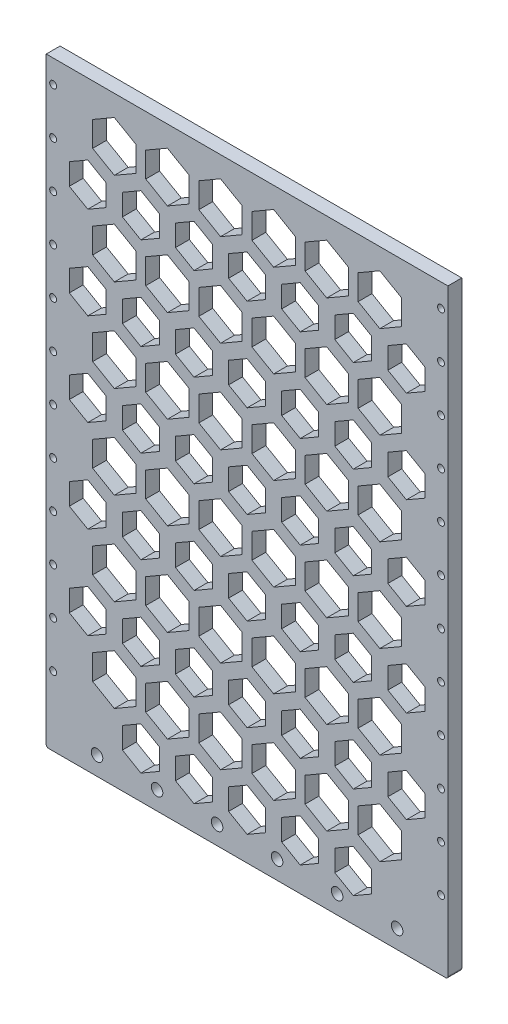
from build123d import *

# Parameters (mm, degrees)
SKETCH1_W           = 174
SKETCH1_H           = 240
BOSS_EXTRUDE1_DEPTH = 6
SKETCH3_R           = 2.5
CUT_EXTRUDE1_DEPTH  = 6
SKETCH4_W           = 174
SKETCH4_H           = 6
BOSS_EXTRUDE2_DEPTH = 20
SKETCH6_R           = 1.5
CUT_EXTRUDE2_DEPTH  = 10
CUT_EXTRUDE3_DEPTH  = 10
FILLET2_R           = 1


with BuildPart() as part:
    # Sketch1 → Boss-Extrude1 (new body)
    with BuildSketch(Plane.XY):
        with Locations((0, -30)):
            Rectangle(SKETCH1_W, SKETCH1_H)
    extrude(amount=BOSS_EXTRUDE1_DEPTH)

    # Sketch3 → Cut-Extrude1 (cut)
    with BuildSketch(Plane.XY.offset(6)):
        with Locations((-65, -142)):
            Circle(SKETCH3_R)
        with Locations((-39, -142)):
            Circle(SKETCH3_R)
        with Locations((-13, -142)):
            Circle(SKETCH3_R)
        with Locations((13, -142)):
            Circle(SKETCH3_R)
        with Locations((39, -142)):
            Circle(SKETCH3_R)
        with Locations((65, -142)):
            Circle(SKETCH3_R)
    extrude(amount=-CUT_EXTRUDE1_DEPTH, mode=Mode.SUBTRACT)

    # Sketch4 → Boss-Extrude2 (add)
    with BuildSketch(Plane(origin=(0, 90, 0), x_dir=(1, 0, 0), z_dir=(0, 1, 0))):
        with Locations((0, -3)):
            Rectangle(SKETCH4_W, SKETCH4_H)
    extrude(amount=BOSS_EXTRUDE2_DEPTH)

    # Sketch6 → Cut-Extrude2 (cut)
    with BuildSketch(Plane.XY.offset(6)):
        with Locations((-84, 100)):
            Circle(SKETCH6_R)
        with Locations((-84, 80)):
            Circle(SKETCH6_R)
        with Locations((-84, 60)):
            Circle(SKETCH6_R)
        with Locations((-84, 40)):
            Circle(SKETCH6_R)
        with Locations((-84, 20)):
            Circle(SKETCH6_R)
        with Locations((-84, 0)):
            Circle(SKETCH6_R)
        with Locations((-84, -20)):
            Circle(SKETCH6_R)
        with Locations((-84, -40)):
            Circle(SKETCH6_R)
        with Locations((-84, -60)):
            Circle(SKETCH6_R)
        with Locations((-84, -80)):
            Circle(SKETCH6_R)
        with Locations((-84, -100)):
            Circle(SKETCH6_R)
        with Locations((-84, -120)):
            Circle(SKETCH6_R)
        with Locations((84, 100)):
            Circle(SKETCH6_R)
        with Locations((84, 80)):
            Circle(SKETCH6_R)
        with Locations((84, 60)):
            Circle(SKETCH6_R)
        with Locations((84, 40)):
            Circle(SKETCH6_R)
        with Locations((84, 20)):
            Circle(SKETCH6_R)
        with Locations((84, 0)):
            Circle(SKETCH6_R)
        with Locations((84, -20)):
            Circle(SKETCH6_R)
        with Locations((84, -40)):
            Circle(SKETCH6_R)
        with Locations((84, -60)):
            Circle(SKETCH6_R)
        with Locations((84, -80)):
            Circle(SKETCH6_R)
        with Locations((84, -100)):
            Circle(SKETCH6_R)
        with Locations((84, -120)):
            Circle(SKETCH6_R)
    extrude(amount=-CUT_EXTRUDE2_DEPTH, mode=Mode.SUBTRACT)

    # Sketch7 → Cut-Extrude3 (cut)
    with BuildSketch(Plane.XY.offset(6)):
        Polygon((-46, 60.762395693), (-38, 65.381197846), (-38, 74.618802154), (-46, 79.237604307), (-54, 74.618802154), (-54, 65.381197846), align=None)
        Polygon((-23, 60.762395693), (-15, 65.381197846), (-15, 74.618802154), (-23, 79.237604307), (-31, 74.618802154), (-31, 65.381197846), align=None)
        Polygon((0, 60.762395693), (8, 65.381197846), (8, 74.618802154), (0, 79.237604307), (-8, 74.618802154), (-8, 65.381197846), align=None)
        Polygon((23, 60.762395693), (31, 65.381197846), (31, 74.618802154), (23, 79.237604307), (15, 74.618802154), (15, 65.381197846), align=None)
        Polygon((46, 60.762395693), (54, 65.381197846), (54, 74.618802154), (46, 79.237604307), (38, 74.618802154), (38, 65.381197846), align=None)
        Polygon((69, 60.762395693), (77, 65.381197846), (77, 74.618802154), (69, 79.237604307), (61, 74.618802154), (61, 65.381197846), align=None)
        Polygon((-46, 20.762395693), (-38, 25.381197846), (-38, 34.618802154), (-46, 39.237604307), (-54, 34.618802154), (-54, 25.381197846), align=None)
        Polygon((-23, 20.762395693), (-15, 25.381197846), (-15, 34.618802154), (-23, 39.237604307), (-31, 34.618802154), (-31, 25.381197846), align=None)
        Polygon((0, 20.762395693), (8, 25.381197846), (8, 34.618802154), (0, 39.237604307), (-8, 34.618802154), (-8, 25.381197846), align=None)
        Polygon((23, 20.762395693), (31, 25.381197846), (31, 34.618802154), (23, 39.237604307), (15, 34.618802154), (15, 25.381197846), align=None)
        Polygon((46, 20.762395693), (54, 25.381197846), (54, 34.618802154), (46, 39.237604307), (38, 34.618802154), (38, 25.381197846), align=None)
        Polygon((69, 20.762395693), (77, 25.381197846), (77, 34.618802154), (69, 39.237604307), (61, 34.618802154), (61, 25.381197846), align=None)
        Polygon((-46, -19.237604307), (-38, -14.618802154), (-38, -5.381197846), (-46, -0.762395693), (-54, -5.381197846), (-54, -14.618802154), align=None)
        Polygon((-23, -19.237604307), (-15, -14.618802154), (-15, -5.381197846), (-23, -0.762395693), (-31, -5.381197846), (-31, -14.618802154), align=None)
        Polygon((0, -19.237604307), (8, -14.618802154), (8, -5.381197846), (0, -0.762395693), (-8, -5.381197846), (-8, -14.618802154), align=None)
        Polygon((23, -19.237604307), (31, -14.618802154), (31, -5.381197846), (23, -0.762395693), (15, -5.381197846), (15, -14.618802154), align=None)
        Polygon((46, -19.237604307), (54, -14.618802154), (54, -5.381197846), (46, -0.762395693), (38, -5.381197846), (38, -14.618802154), align=None)
        Polygon((69, -19.237604307), (77, -14.618802154), (77, -5.381197846), (69, -0.762395693), (61, -5.381197846), (61, -14.618802154), align=None)
        Polygon((-46, -59.237604307), (-38, -54.618802154), (-38, -45.381197846), (-46, -40.762395693), (-54, -45.381197846), (-54, -54.618802154), align=None)
        Polygon((-23, -59.237604307), (-15, -54.618802154), (-15, -45.381197846), (-23, -40.762395693), (-31, -45.381197846), (-31, -54.618802154), align=None)
        Polygon((0, -59.237604307), (8, -54.618802154), (8, -45.381197846), (0, -40.762395693), (-8, -45.381197846), (-8, -54.618802154), align=None)
        Polygon((23, -59.237604307), (31, -54.618802154), (31, -45.381197846), (23, -40.762395693), (15, -45.381197846), (15, -54.618802154), align=None)
        Polygon((46, -59.237604307), (54, -54.618802154), (54, -45.381197846), (46, -40.762395693), (38, -45.381197846), (38, -54.618802154), align=None)
        Polygon((69, -59.237604307), (77, -54.618802154), (77, -45.381197846), (69, -40.762395693), (61, -45.381197846), (61, -54.618802154), align=None)
        Polygon((-46, -99.237604307), (-38, -94.618802154), (-38, -85.381197846), (-46, -80.762395693), (-54, -85.381197846), (-54, -94.618802154), align=None)
        Polygon((-23, -99.237604307), (-15, -94.618802154), (-15, -85.381197846), (-23, -80.762395693), (-31, -85.381197846), (-31, -94.618802154), align=None)
        Polygon((0, -99.237604307), (8, -94.618802154), (8, -85.381197846), (0, -80.762395693), (-8, -85.381197846), (-8, -94.618802154), align=None)
        Polygon((23, -99.237604307), (31, -94.618802154), (31, -85.381197846), (23, -80.762395693), (15, -85.381197846), (15, -94.618802154), align=None)
        Polygon((46, -99.237604307), (54, -94.618802154), (54, -85.381197846), (46, -80.762395693), (38, -85.381197846), (38, -94.618802154), align=None)
        Polygon((69, -99.237604307), (77, -94.618802154), (77, -85.381197846), (69, -80.762395693), (61, -85.381197846), (61, -94.618802154), align=None)
        Polygon((-46, -139.237604307), (-38, -134.618802154), (-38, -125.381197846), (-46, -120.762395693), (-54, -125.381197846), (-54, -134.618802154), align=None)
        Polygon((-23, -139.237604307), (-15, -134.618802154), (-15, -125.381197846), (-23, -120.762395693), (-31, -125.381197846), (-31, -134.618802154), align=None)
        Polygon((0, -139.237604307), (8, -134.618802154), (8, -125.381197846), (0, -120.762395693), (-8, -125.381197846), (-8, -134.618802154), align=None)
        Polygon((23, -139.237604307), (31, -134.618802154), (31, -125.381197846), (23, -120.762395693), (15, -125.381197846), (15, -134.618802154), align=None)
        Polygon((46, -139.237604307), (54, -134.618802154), (54, -125.381197846), (46, -120.762395693), (38, -125.381197846), (38, -134.618802154), align=None)
        Polygon((-69, 60.762395693), (-61, 65.381197846), (-61, 74.618802154), (-69, 79.237604307), (-77, 74.618802154), (-77, 65.381197846), align=None)
        Polygon((-69, 20.762395693), (-61, 25.381197846), (-61, 34.618802154), (-69, 39.237604307), (-77, 34.618802154), (-77, 25.381197846), align=None)
        Polygon((-69, -19.237604307), (-61, -14.618802154), (-61, -5.381197846), (-69, -0.762395693), (-77, -5.381197846), (-77, -14.618802154), align=None)
        Polygon((-69, -59.237604307), (-61, -54.618802154), (-61, -45.381197846), (-69, -40.762395693), (-77, -45.381197846), (-77, -54.618802154), align=None)
        Polygon((-69, -99.237604307), (-61, -94.618802154), (-61, -85.381197846), (-69, -80.762395693), (-77, -85.381197846), (-77, -94.618802154), align=None)
        Polygon((-34.5, 79.237604307), (-25.108983849, 84.65951001), (-25.108983849, 95.503321416), (-34.5, 100.925227119), (-43.891016151, 95.503321416), (-43.891016151, 84.65951001), align=None)
        Polygon((-11.5, 79.237604307), (-2.108983849, 84.65951001), (-2.108983849, 95.503321416), (-11.5, 100.925227119), (-20.891016151, 95.503321416), (-20.891016151, 84.65951001), align=None)
        Polygon((11.5, 79.237604307), (20.891016151, 84.65951001), (20.891016151, 95.503321416), (11.5, 100.925227119), (2.108983849, 95.503321416), (2.108983849, 84.65951001), align=None)
        Polygon((34.5, 79.237604307), (43.891016151, 84.65951001), (43.891016151, 95.503321416), (34.5, 100.925227119), (25.108983849, 95.503321416), (25.108983849, 84.65951001), align=None)
        Polygon((57.5, 79.237604307), (66.891016151, 84.65951001), (66.891016151, 95.503321416), (57.5, 100.925227119), (48.108983849, 95.503321416), (48.108983849, 84.65951001), align=None)
        Polygon((-34.5, 39.237604307), (-25.108983849, 44.65951001), (-25.108983849, 55.503321416), (-34.5, 60.925227119), (-43.891016151, 55.503321416), (-43.891016151, 44.65951001), align=None)
        Polygon((-11.5, 39.237604307), (-2.108983849, 44.65951001), (-2.108983849, 55.503321416), (-11.5, 60.925227119), (-20.891016151, 55.503321416), (-20.891016151, 44.65951001), align=None)
        Polygon((11.5, 39.237604307), (20.891016151, 44.65951001), (20.891016151, 55.503321416), (11.5, 60.925227119), (2.108983849, 55.503321416), (2.108983849, 44.65951001), align=None)
        Polygon((34.5, 39.237604307), (43.891016151, 44.65951001), (43.891016151, 55.503321416), (34.5, 60.925227119), (25.108983849, 55.503321416), (25.108983849, 44.65951001), align=None)
        Polygon((57.5, 39.237604307), (66.891016151, 44.65951001), (66.891016151, 55.503321416), (57.5, 60.925227119), (48.108983849, 55.503321416), (48.108983849, 44.65951001), align=None)
        Polygon((-34.5, -0.762395693), (-25.108983849, 4.65951001), (-25.108983849, 15.503321416), (-34.5, 20.925227119), (-43.891016151, 15.503321416), (-43.891016151, 4.65951001), align=None)
        Polygon((-11.5, -0.762395693), (-2.108983849, 4.65951001), (-2.108983849, 15.503321416), (-11.5, 20.925227119), (-20.891016151, 15.503321416), (-20.891016151, 4.65951001), align=None)
        Polygon((11.5, -0.762395693), (20.891016151, 4.65951001), (20.891016151, 15.503321416), (11.5, 20.925227119), (2.108983849, 15.503321416), (2.108983849, 4.65951001), align=None)
        Polygon((34.5, -0.762395693), (43.891016151, 4.65951001), (43.891016151, 15.503321416), (34.5, 20.925227119), (25.108983849, 15.503321416), (25.108983849, 4.65951001), align=None)
        Polygon((57.5, -0.762395693), (66.891016151, 4.65951001), (66.891016151, 15.503321416), (57.5, 20.925227119), (48.108983849, 15.503321416), (48.108983849, 4.65951001), align=None)
        Polygon((-34.5, -40.762395693), (-25.108983849, -35.34048999), (-25.108983849, -24.496678584), (-34.5, -19.074772881), (-43.891016151, -24.496678584), (-43.891016151, -35.34048999), align=None)
        Polygon((-11.5, -40.762395693), (-2.108983849, -35.34048999), (-2.108983849, -24.496678584), (-11.5, -19.074772881), (-20.891016151, -24.496678584), (-20.891016151, -35.34048999), align=None)
        Polygon((11.5, -40.762395693), (20.891016151, -35.34048999), (20.891016151, -24.496678584), (11.5, -19.074772881), (2.108983849, -24.496678584), (2.108983849, -35.34048999), align=None)
        Polygon((34.5, -40.762395693), (43.891016151, -35.34048999), (43.891016151, -24.496678584), (34.5, -19.074772881), (25.108983849, -24.496678584), (25.108983849, -35.34048999), align=None)
        Polygon((57.5, -40.762395693), (66.891016151, -35.34048999), (66.891016151, -24.496678584), (57.5, -19.074772881), (48.108983849, -24.496678584), (48.108983849, -35.34048999), align=None)
        Polygon((-34.5, -80.762395693), (-25.108983849, -75.34048999), (-25.108983849, -64.496678584), (-34.5, -59.074772881), (-43.891016151, -64.496678584), (-43.891016151, -75.34048999), align=None)
        Polygon((-11.5, -80.762395693), (-2.108983849, -75.34048999), (-2.108983849, -64.496678584), (-11.5, -59.074772881), (-20.891016151, -64.496678584), (-20.891016151, -75.34048999), align=None)
        Polygon((11.5, -80.762395693), (20.891016151, -75.34048999), (20.891016151, -64.496678584), (11.5, -59.074772881), (2.108983849, -64.496678584), (2.108983849, -75.34048999), align=None)
        Polygon((34.5, -80.762395693), (43.891016151, -75.34048999), (43.891016151, -64.496678584), (34.5, -59.074772881), (25.108983849, -64.496678584), (25.108983849, -75.34048999), align=None)
        Polygon((57.5, -80.762395693), (66.891016151, -75.34048999), (66.891016151, -64.496678584), (57.5, -59.074772881), (48.108983849, -64.496678584), (48.108983849, -75.34048999), align=None)
        Polygon((-34.5, -120.762395693), (-25.108983849, -115.34048999), (-25.108983849, -104.496678584), (-34.5, -99.074772881), (-43.891016151, -104.496678584), (-43.891016151, -115.34048999), align=None)
        Polygon((-11.5, -120.762395693), (-2.108983849, -115.34048999), (-2.108983849, -104.496678584), (-11.5, -99.074772881), (-20.891016151, -104.496678584), (-20.891016151, -115.34048999), align=None)
        Polygon((11.5, -120.762395693), (20.891016151, -115.34048999), (20.891016151, -104.496678584), (11.5, -99.074772881), (2.108983849, -104.496678584), (2.108983849, -115.34048999), align=None)
        Polygon((34.5, -120.762395693), (43.891016151, -115.34048999), (43.891016151, -104.496678584), (34.5, -99.074772881), (25.108983849, -104.496678584), (25.108983849, -115.34048999), align=None)
        Polygon((57.5, -120.762395693), (66.891016151, -115.34048999), (66.891016151, -104.496678584), (57.5, -99.074772881), (48.108983849, -104.496678584), (48.108983849, -115.34048999), align=None)
        Polygon((-57.5, 79.237604307), (-48.108983849, 84.65951001), (-48.108983849, 95.503321416), (-57.5, 100.925227119), (-66.891016151, 95.503321416), (-66.891016151, 84.65951001), align=None)
        Polygon((-57.5, 39.237604307), (-48.108983849, 44.65951001), (-48.108983849, 55.503321416), (-57.5, 60.925227119), (-66.891016151, 55.503321416), (-66.891016151, 44.65951001), align=None)
        Polygon((-57.5, -0.762395693), (-48.108983849, 4.65951001), (-48.108983849, 15.503321416), (-57.5, 20.925227119), (-66.891016151, 15.503321416), (-66.891016151, 4.65951001), align=None)
        Polygon((-57.5, -40.762395693), (-48.108983849, -35.34048999), (-48.108983849, -24.496678584), (-57.5, -19.074772881), (-66.891016151, -24.496678584), (-66.891016151, -35.34048999), align=None)
        Polygon((-57.5, -80.762395693), (-48.108983849, -75.34048999), (-48.108983849, -64.496678584), (-57.5, -59.074772881), (-66.891016151, -64.496678584), (-66.891016151, -75.34048999), align=None)
        Polygon((-57.5, -120.762395693), (-48.108983849, -115.34048999), (-48.108983849, -104.496678584), (-57.5, -99.074772881), (-66.891016151, -104.496678584), (-66.891016151, -115.34048999), align=None)
    extrude(amount=-CUT_EXTRUDE3_DEPTH, mode=Mode.SUBTRACT)

    # Fillet2
    fillet2_edges = [part.edges().sort_by_distance(p)[0] for p in [
        (0, -150, 0),
        (87, -150, 3),
        (-87, -150, 3),
    ]]
    fillet(fillet2_edges, radius=FILLET2_R)


solid = part.part
